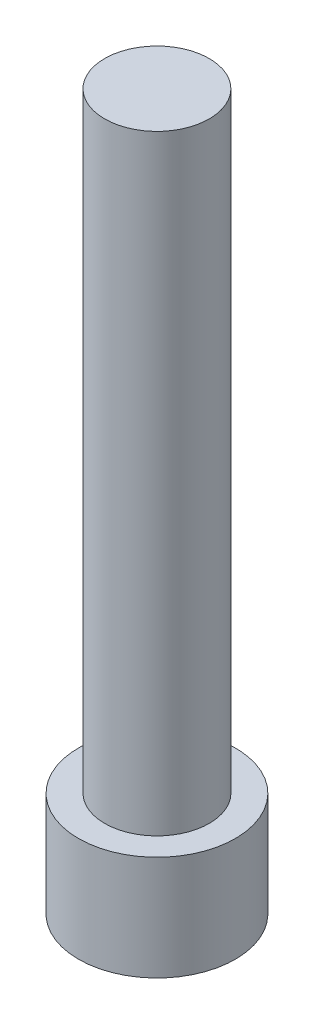
from build123d import *

# Parameters (mm, degrees)
SKETCH1_R           = 9
BOSS_EXTRUDE1_DEPTH = 12
SKETCH2_R           = 6
BOSS_EXTRUDE2_DEPTH = 70


with BuildPart() as part:
    # Sketch1 → Boss-Extrude1 (new body)
    with BuildSketch(Plane(origin=(0, 0, 0), x_dir=(1, 0, 0), z_dir=(0, 1, 0))):
        Circle(SKETCH1_R)
    extrude(amount=BOSS_EXTRUDE1_DEPTH)

    # Sketch2 → Boss-Extrude2 (add)
    with BuildSketch(Plane(origin=(0, 12, 0), x_dir=(1, 0, 0), z_dir=(0, 1, 0))):
        Circle(SKETCH2_R)
    extrude(amount=BOSS_EXTRUDE2_DEPTH)


solid = part.part
